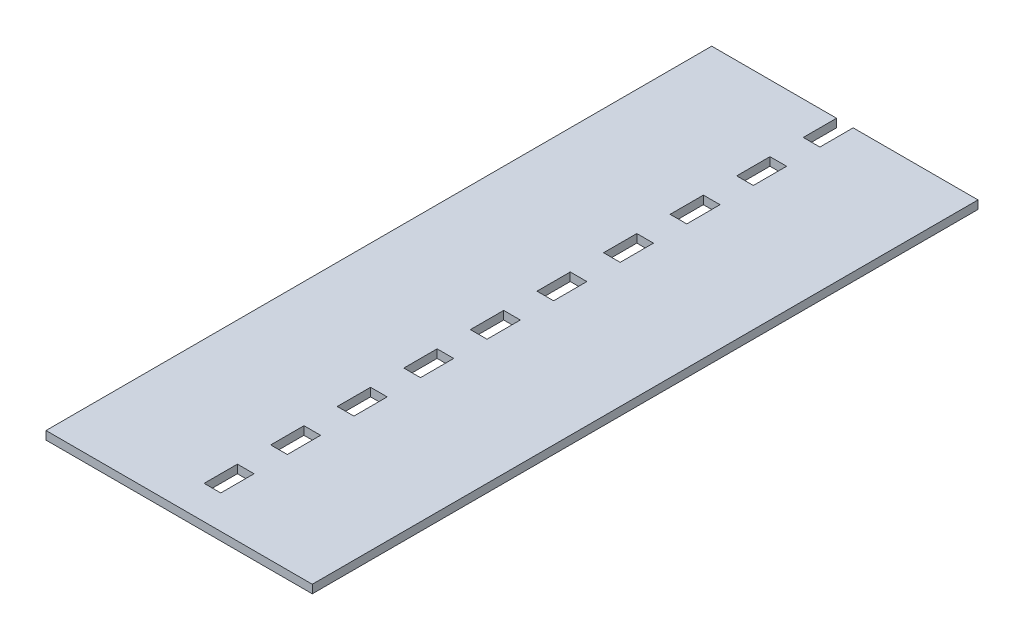
from build123d import *

# Parameters (mm, degrees)
SKETCH1_W           = 50
SKETCH1_H           = 100
BOSS_EXTRUDE1_DEPTH = 25


with BuildPart() as part:
    # Sketch1 → Boss-Extrude1 (new body)
    with BuildSketch(Plane(origin=(0, 0, 0), x_dir=(1, 0, 0), z_dir=(0, 1, 0))):
        Polygon((-457.962648343, 1946.847529943), (-457.962648343, -53.152470057), (342.037351657, -53.152470057), (342.037351657, 1946.847529943), (-32.962648343, 1946.847529943), (-32.962648343, 1846.847529943), (-82.962648343, 1846.847529943), (-82.962648343, 1946.847529943), align=None)
        with Locations((-57.962648343, 1696.847529943)):
            Rectangle(SKETCH1_W, SKETCH1_H, mode=Mode.SUBTRACT)
        with Locations((-57.962648343, 1496.847529943)):
            Rectangle(SKETCH1_W, SKETCH1_H, mode=Mode.SUBTRACT)
        with Locations((-57.962648343, 1296.847529943)):
            Rectangle(SKETCH1_W, SKETCH1_H, mode=Mode.SUBTRACT)
        with Locations((-57.962648343, 1096.847529943)):
            Rectangle(SKETCH1_W, SKETCH1_H, mode=Mode.SUBTRACT)
        with Locations((-57.962648343, 896.847529943)):
            Rectangle(SKETCH1_W, SKETCH1_H, mode=Mode.SUBTRACT)
        with Locations((-57.962648343, 696.847529943)):
            Rectangle(SKETCH1_W, SKETCH1_H, mode=Mode.SUBTRACT)
        with Locations((-57.962648343, 496.847529943)):
            Rectangle(SKETCH1_W, SKETCH1_H, mode=Mode.SUBTRACT)
        with Locations((-57.962648343, 296.847529943)):
            Rectangle(SKETCH1_W, SKETCH1_H, mode=Mode.SUBTRACT)
        with Locations((-57.962648343, 96.847529943)):
            Rectangle(SKETCH1_W, SKETCH1_H, mode=Mode.SUBTRACT)
    extrude(amount=BOSS_EXTRUDE1_DEPTH)


solid = part.part
